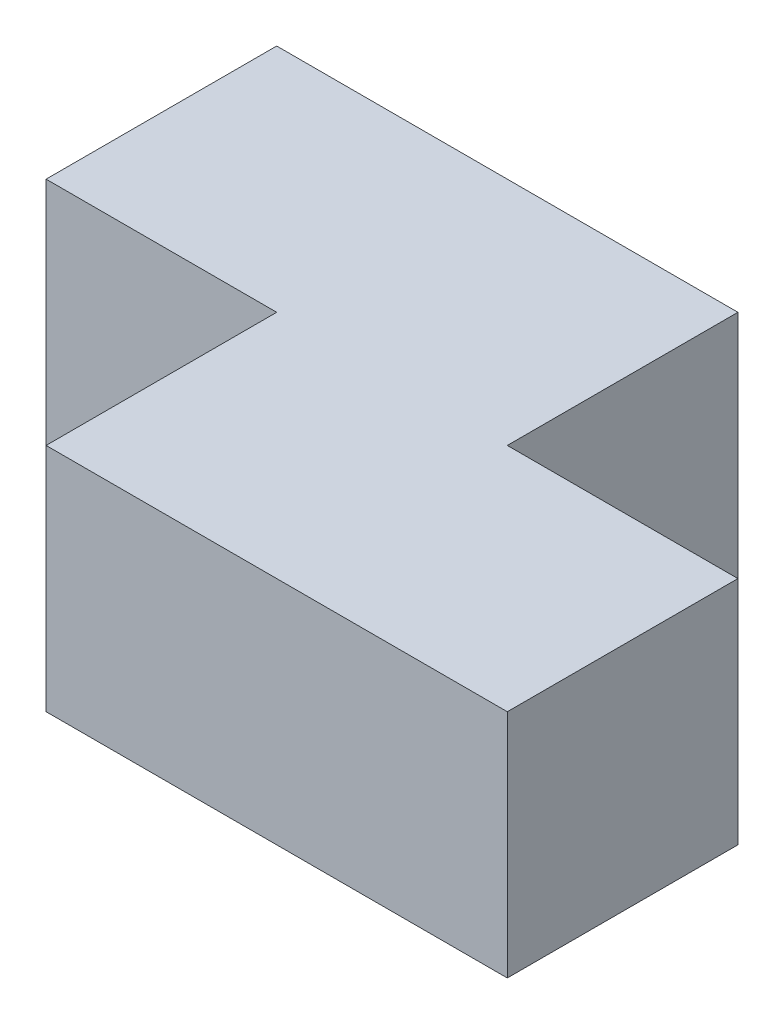
from build123d import *

# Parameters (mm, degrees)
SKETCH1_W           = 76.2
SKETCH1_H           = 50.8
BOSS_EXTRUDE1_DEPTH = 25.4
SKETCH2_W           = 25.4
SKETCH2_H           = 25.4
CUT_EXTRUDE1_DEPTH  = 26.4
SKETCH3_W           = 25.4
SKETCH3_H           = 25.4
CUT_EXTRUDE2_DEPTH  = 26.4


with BuildPart() as part:
    # Sketch1 → Boss-Extrude1 (new body)
    with BuildSketch(Plane(origin=(0, 0, 0), x_dir=(1, 0, 0), z_dir=(0, 1, 0))):
        Rectangle(SKETCH1_W, SKETCH1_H)
    extrude(amount=BOSS_EXTRUDE1_DEPTH)

    # Sketch2 → Cut-Extrude1 (cut, through all)
    with BuildSketch(Plane(origin=(0, 25.4, 0), x_dir=(1, 0, 0), z_dir=(0, 1, 0))):
        with Locations((-25.4, -12.7)):
            Rectangle(SKETCH2_W, SKETCH2_H)
    extrude(amount=-CUT_EXTRUDE1_DEPTH, mode=Mode.SUBTRACT)

    # Sketch3 → Cut-Extrude2 (cut, through all)
    with BuildSketch(Plane(origin=(0, 25.4, 0), x_dir=(1, 0, 0), z_dir=(0, 1, 0))):
        with Locations((25.4, 12.7)):
            Rectangle(SKETCH3_W, SKETCH3_H)
    extrude(amount=-CUT_EXTRUDE2_DEPTH, mode=Mode.SUBTRACT)


solid = part.part
